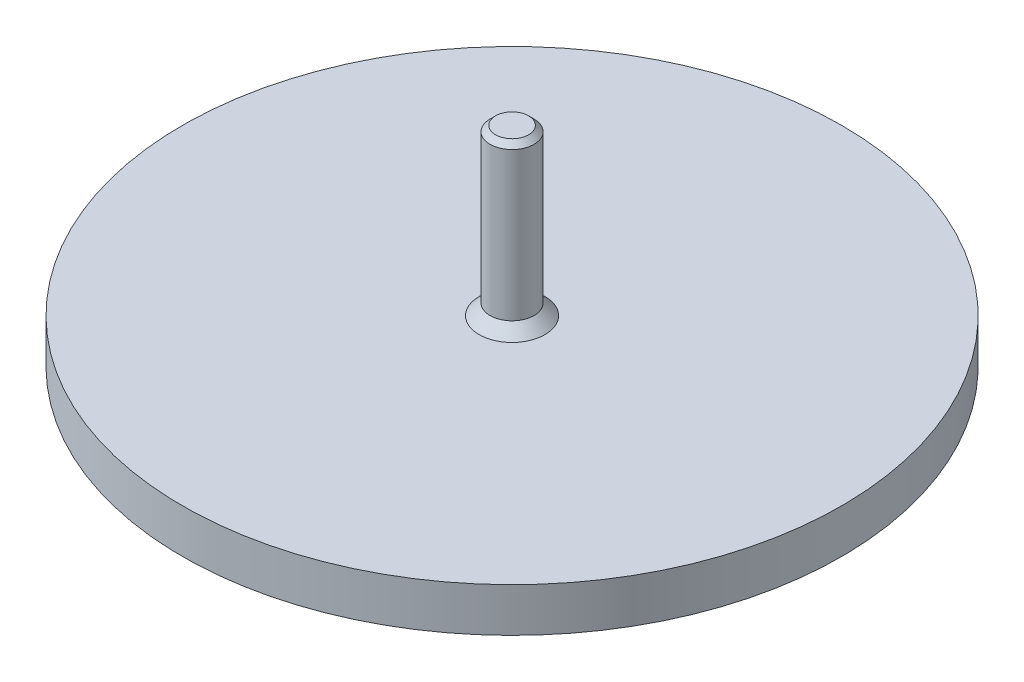
from build123d import *

# Parameters (mm, degrees)
CHANFREIN1_SIZE = 1
CHANFREIN2_SIZE = 0.5


with BuildPart() as part:
    # Esquisse1 → Révolution1 (revolve)
    with BuildSketch(Plane.XY):
        Polygon((0, 0), (-30, 0), (-30, 4), (-2, 4), (-2, 19), (0, 19), align=None)
    revolve(axis=Axis((0, 0, 0), (0, 1, 0)))

    # Chanfrein1
    chanfrein1_edges = [part.edges().sort_by_distance(p)[0] for p in [
        (2, 4, 0),
    ]]
    chamfer(chanfrein1_edges, length=CHANFREIN1_SIZE)

    # Chanfrein2
    chanfrein2_edges = [part.edges().sort_by_distance(p)[0] for p in [
        (2, 19, 0),
    ]]
    chamfer(chanfrein2_edges, length=CHANFREIN2_SIZE)


solid = part.part
